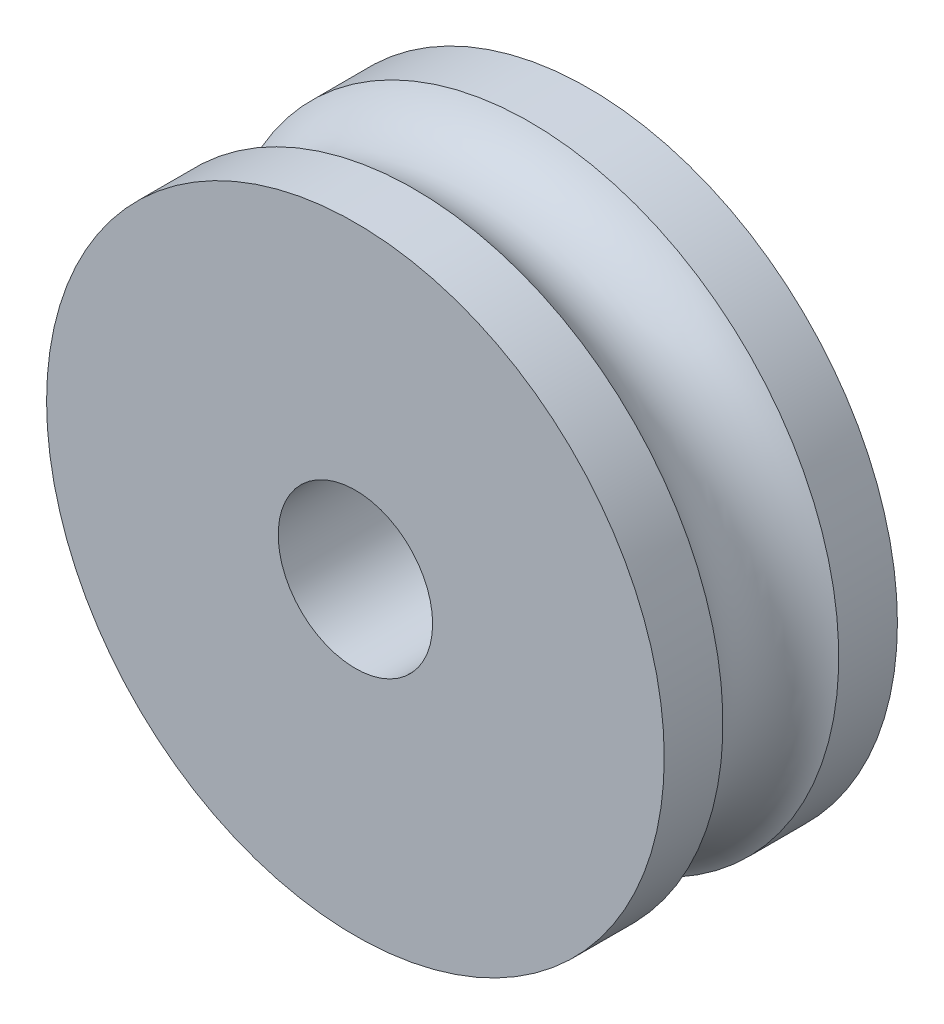
from build123d import *

# Parameters (mm, degrees)
SKETCH1_R           = 12.7
SKETCH1_R_2         = 3.175
BOSS_EXTRUDE1_DEPTH = 9.5885


with BuildPart() as part:
    # Sketch1 → Boss-Extrude1 (new body)
    with BuildSketch(Plane.XY):
        Circle(SKETCH1_R)
        Circle(SKETCH1_R_2, mode=Mode.SUBTRACT)
    extrude(amount=BOSS_EXTRUDE1_DEPTH)

    # Sketch2 → Cut-Revolve1 (revolve, cut)
    with BuildSketch(Plane(origin=(0, 0, 0), x_dir=(0, 0, -1), z_dir=(1, 0, 0))):
        with BuildLine():
            Line((-2.413, 12.7), (-7.1755, 12.7))
            ThreePointArc((-7.1755, 12.7), (-4.79425, 11.291518836), (-2.413, 12.7))
        make_face()
    revolve(axis=Axis((0, 0, -0.631825), (0, 0, 1)), mode=Mode.SUBTRACT)


solid = part.part
